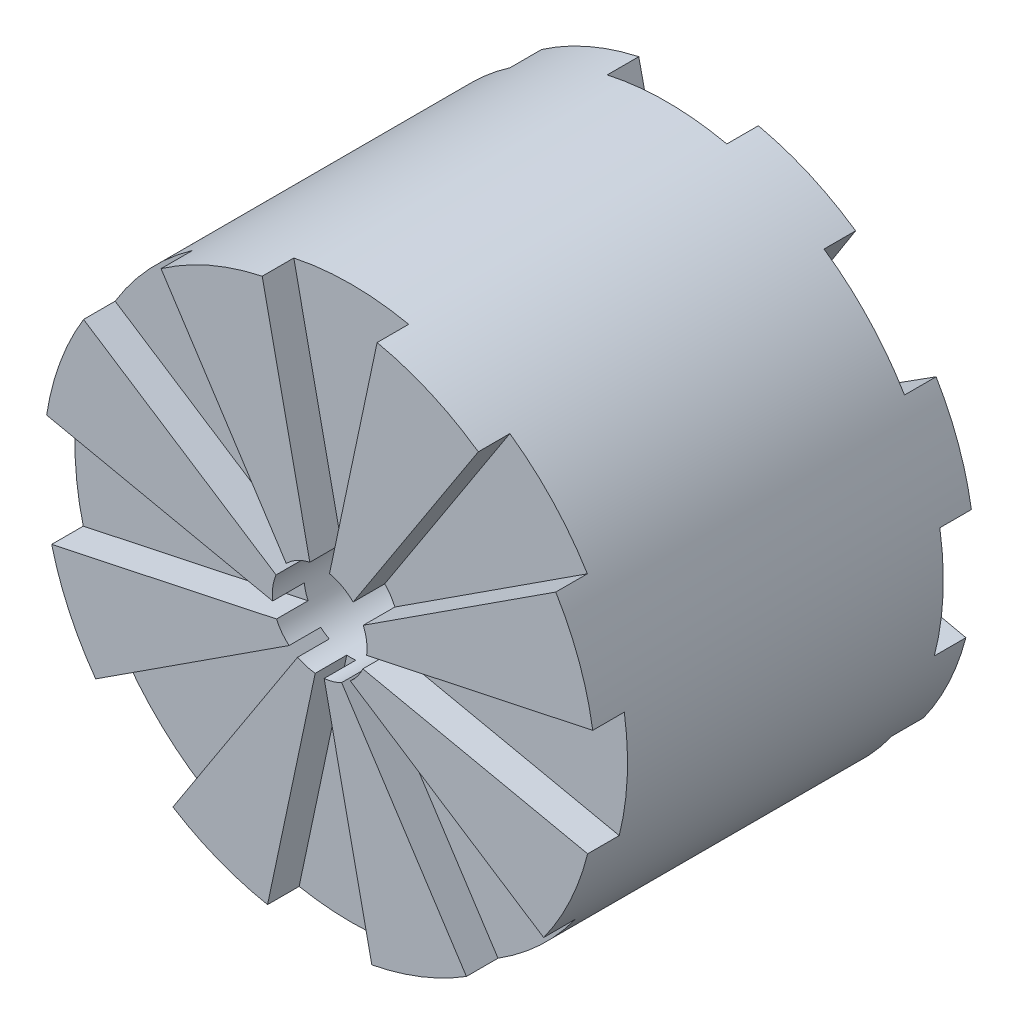
from build123d import *

# Parameters (mm, degrees)
SKETCH1_R           = 87.5
BOSS_EXTRUDE1_DEPTH = 120
CUT_EXTRUDE1_DEPTH  = 10
CIRPATTERN1_COUNT   = 8
CUT_EXTRUDE2_DEPTH  = 10
CIRPATTERN2_COUNT   = 8
SKETCH5_R           = 15
CUT_EXTRUDE3_DEPTH  = 121


with BuildPart() as part:
    # Sketch1 → Boss-Extrude1 (new body)
    with BuildSketch(Plane.XY):
        Circle(SKETCH1_R)
    extrude(amount=BOSS_EXTRUDE1_DEPTH)

    # Sketch2 → Cut-Extrude1 (cut)
    with BuildSketch(Plane.XY.offset(120)):
        Polygon((-104.60287609, 492.11784039), (-18.192272947, 85.587915064), (0, 0), (18.192272947, 85.587915064), (104.60287609, 492.11784039), (104.60287609, 1323.341931767), (-104.60287609, 1323.341931767), align=None)
    cut_extrude1 = extrude(amount=-CUT_EXTRUDE1_DEPTH, mode=Mode.SUBTRACT)

    # CirPattern1: Cut-Extrude1 ×8 about axis
    cirpattern1_axis = Axis((0, -4.136271665, 0), (0, 0, 1))
    for i in range(1, CIRPATTERN1_COUNT):
        add(cut_extrude1.rotate(cirpattern1_axis, i * 360 / CIRPATTERN1_COUNT), mode=Mode.SUBTRACT)

    # Sketch4 → Cut-Extrude2 (cut)
    with BuildSketch(Plane(origin=(0, 0, 0), x_dir=(-1, 0, 0), z_dir=(0, 0, -1))):
        Polygon((-109.002412997, 491.678111226), (-18.93846622, 85.425900623), (0, 0), (18.93846622, 85.425900623), (109.002412997, 491.678111226), (109.002412997, 1323.909745158), (-109.002412997, 1323.909745158), align=None)
    cut_extrude2 = extrude(amount=-CUT_EXTRUDE2_DEPTH, mode=Mode.SUBTRACT)

    # CirPattern2: Cut-Extrude2 ×8 about axis
    cirpattern2_axis = Axis((0, -4.318782825, 0), (0, 0, 1))
    for i in range(1, CIRPATTERN2_COUNT):
        add(cut_extrude2.rotate(cirpattern2_axis, i * 360 / CIRPATTERN2_COUNT), mode=Mode.SUBTRACT)

    # Sketch5 → Cut-Extrude3 (cut, through all)
    with BuildSketch(Plane.XY.offset(120)):
        Circle(SKETCH5_R)
    extrude(amount=-CUT_EXTRUDE3_DEPTH, mode=Mode.SUBTRACT)


solid = part.part
